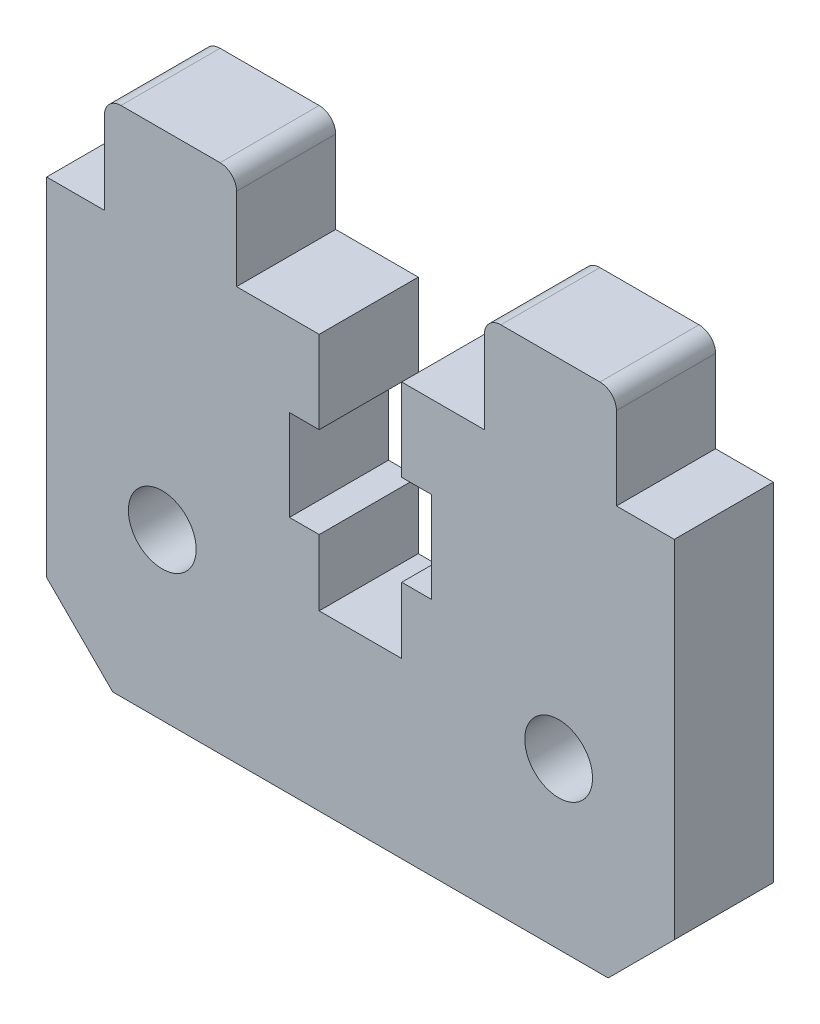
from build123d import *

# Parameters (mm, degrees)
ESQUISSE1_W             = 38
ESQUISSE1_H             = 25
BOSS_EXTRU_1_DEPTH      = 6
ENL_V_MAT_EXTRU_1_DEPTH = 6
BOSS_EXTRU_2_DEPTH      = 6
ESQUISSE4_R             = 2.052376102
ENL_V_MAT_EXTRU_2_DEPTH = 6
CHANFREIN2_SIZE         = 4


with BuildPart() as part:
    # Esquisse1 → Boss.-Extru.1 (new body)
    with BuildSketch(Plane.XY):
        Rectangle(ESQUISSE1_W, ESQUISSE1_H)
    extrude(amount=BOSS_EXTRU_1_DEPTH)

    # Esquisse2 → Enlèv. mat.-Extru.1 (cut)
    with BuildSketch(Plane.XY.offset(6)):
        Polygon((2.5, 12.5), (-2.5, 12.5), (-2.5, 7.5), (-4.3, 7.5), (-4.3, 2), (-2.5, 2), (-2.5, -2), (2.5, -2), (2.5, 2), (4.3, 2), (4.3, 7.5), (2.5, 7.5), align=None)
    extrude(amount=-ENL_V_MAT_EXTRU_1_DEPTH, mode=Mode.SUBTRACT)

    # Esquisse2_3 → Boss.-Extru.2 (add)
    with BuildSketch(Plane.XY.offset(6)):
        with BuildLine():
            Line((7.5, 17.5), (7.5, 12.5))
            Line((7.5, 12.5), (15.5, 12.5))
            Line((15.5, 12.5), (15.5, 17.5))
            ThreePointArc((15.5, 17.5), (15.207106781, 18.207106781), (14.5, 18.5))
            Line((14.5, 18.5), (8.5, 18.5))
            ThreePointArc((8.5, 18.5), (7.792893219, 18.207106781), (7.5, 17.5))
        make_face()
        with BuildLine():
            Line((-15.5, 17.5), (-15.5, 12.5))
            Line((-15.5, 12.5), (-7.5, 12.5))
            Line((-7.5, 12.5), (-7.5, 17.5))
            ThreePointArc((-7.5, 17.5), (-7.792893219, 18.207106781), (-8.5, 18.5))
            Line((-8.5, 18.5), (-14.5, 18.5))
            ThreePointArc((-14.5, 18.5), (-15.207106781, 18.207106781), (-15.5, 17.5))
        make_face()
    extrude(amount=-BOSS_EXTRU_2_DEPTH)

    # Esquisse4 → Enlèv. mat.-Extru.2 (cut)
    with BuildSketch(Plane.XY.offset(6)):
        with Locations((-12, -2.5)):
            Circle(ESQUISSE4_R)
    enl_v_mat_extru_2 = extrude(amount=-ENL_V_MAT_EXTRU_2_DEPTH, mode=Mode.SUBTRACT)

    # Symétrie7: Enlèv. mat.-Extru.2 across plane
    add(enl_v_mat_extru_2.mirror(Plane(origin=(0, 0, 0), x_dir=(0, 0, 1), z_dir=(1, 0, 0))), mode=Mode.SUBTRACT)

    # Chanfrein2
    chanfrein2_edges = [part.edges().sort_by_distance(p)[0] for p in [
        (-19, -12.5, 3),
        (19, -12.5, 3),
    ]]
    chamfer(chanfrein2_edges, length=CHANFREIN2_SIZE)


solid = part.part
